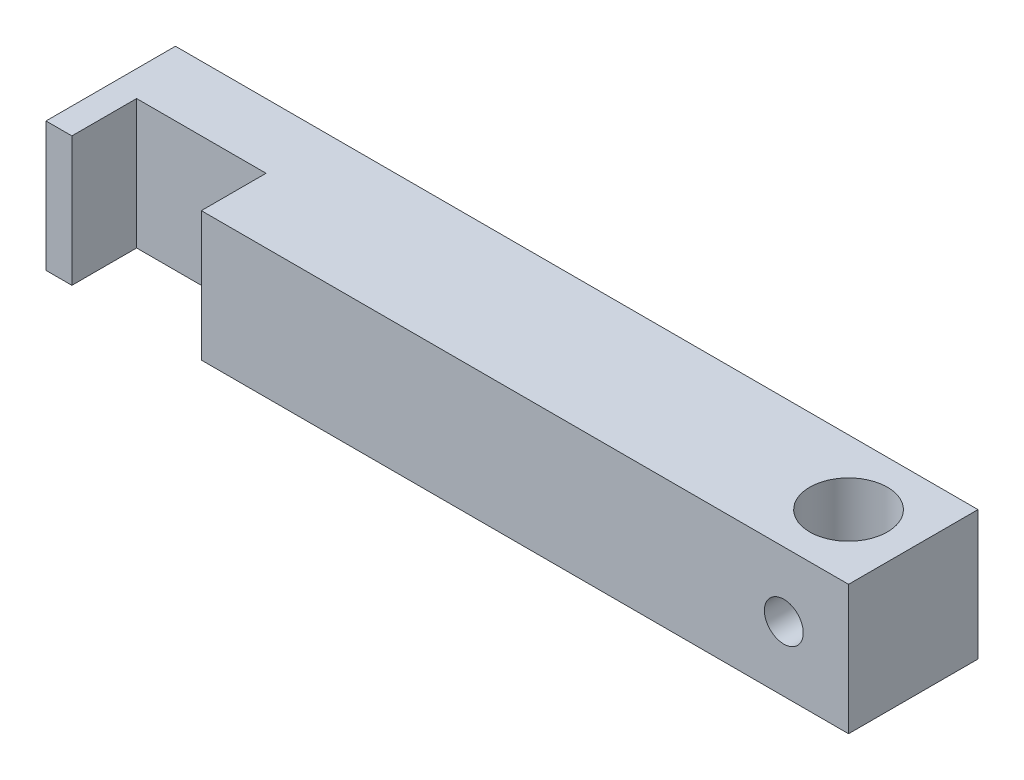
from build123d import *

# Parameters (mm, degrees)
SKETCH_1_R          = 3
EXTRUDE_1_DEPTH     = 5
SKETCH_3_R          = 1.5
CUT_EXTRUDE_1_DEPTH = 11


with BuildPart() as part:
    # 草圖1 → 填料-伸長1 (new body, symmetric)
    with BuildSketch(Plane(origin=(0, 0, 0), x_dir=(1, 0, 0), z_dir=(0, 1, 0))):
        Polygon((-55, -5), (-55, 0), (-45, 0), (-45, -5), (5, -5), (5, 5), (-57, 5), (-57, -5), align=None)
        Circle(SKETCH_1_R, mode=Mode.SUBTRACT)
    extrude(amount=EXTRUDE_1_DEPTH, both=True)

    # 草圖3 → 除料-伸長1 (cut, through all)
    with BuildSketch(Plane.XY.offset(5)):
        Circle(SKETCH_3_R)
    extrude(amount=-CUT_EXTRUDE_1_DEPTH, mode=Mode.SUBTRACT)


solid = part.part
